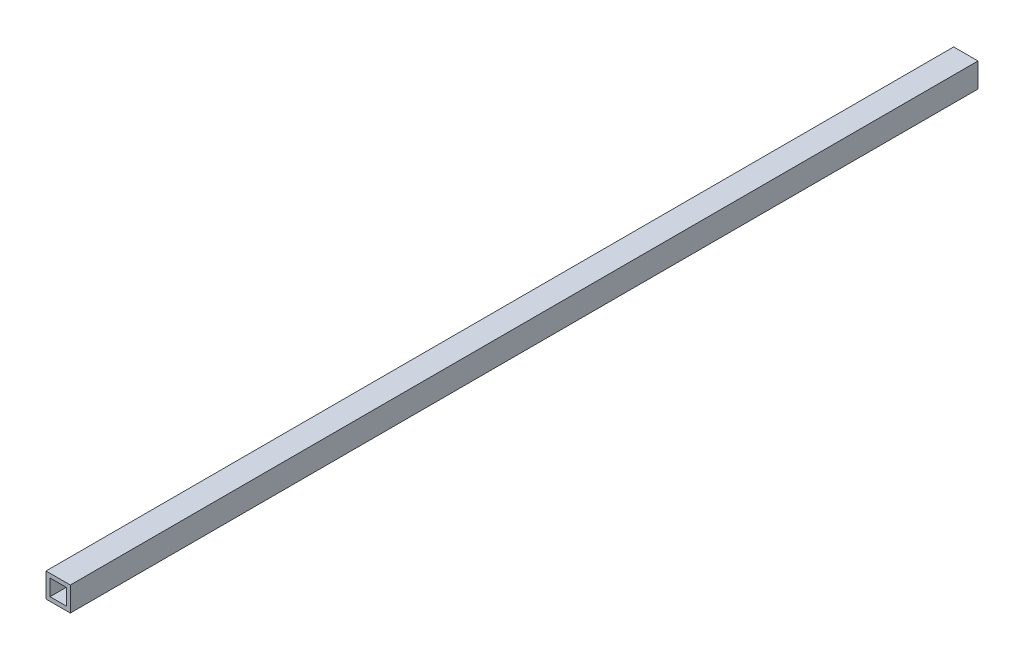
from build123d import *

# Parameters (mm, degrees)
SKETCH1_W           = 19.05
SKETCH1_H           = 19.05
BOSS_EXTRUDE1_DEPTH = 711.2
CUT_EXTRUDE1_REACH  = 713.2
SKETCH2_W           = 12.7
SKETCH2_H           = 12.7


with BuildPart() as part:
    # Sketch1 → Boss-Extrude1 (new body)
    with BuildSketch(Plane.XY):
        Rectangle(SKETCH1_W, SKETCH1_H)
    extrude(amount=-BOSS_EXTRUDE1_DEPTH)

    # Sketch2 → Cut-Extrude1 (cut, up to next)
    with BuildSketch(Plane.XY, mode=Mode.PRIVATE) as cut_extrude1_sk1:
        Rectangle(SKETCH2_W, SKETCH2_H)
    cut_extrude1_tool1 = extrude(cut_extrude1_sk1.sketch, amount=-CUT_EXTRUDE1_REACH, mode=Mode.PRIVATE) & part.part
    add(cut_extrude1_tool1.solids().sort_by_distance((0, 0, 0))[0], mode=Mode.SUBTRACT)


solid = part.part
